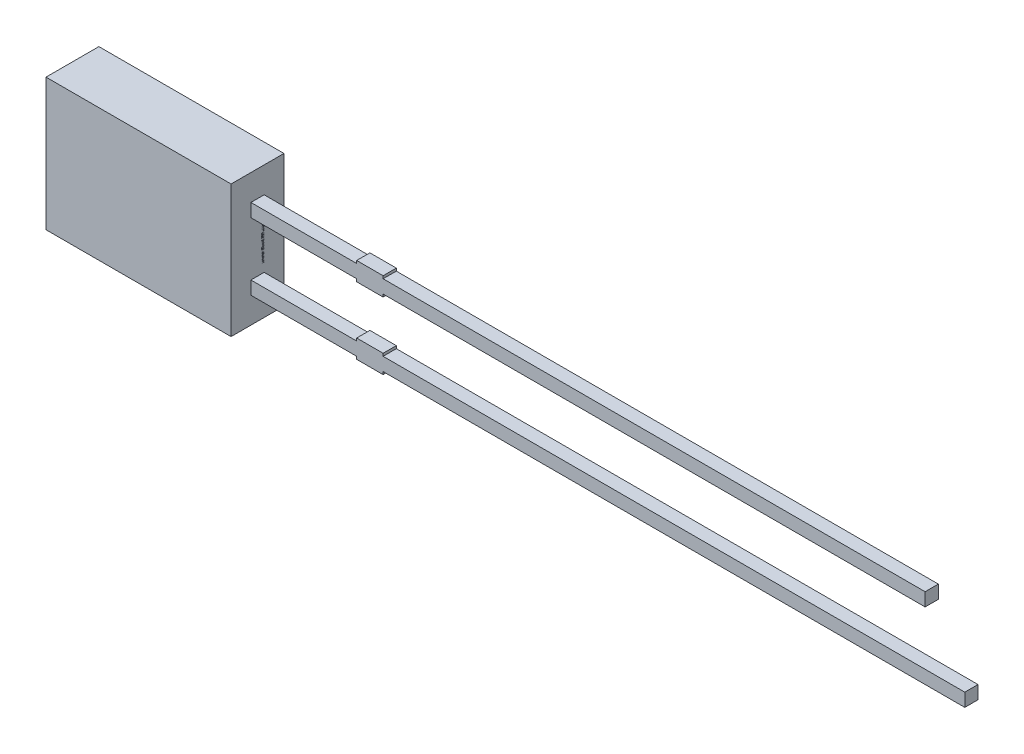
from build123d import *

# Parameters (mm, degrees)
SKETCH1_W          = 7
SKETCH1_H          = 5
EXTRUDE1_DEPTH     = 1
SKETCH1_4_W        = 4
SKETCH1_4_H        = 0.5
SKETCH1_4_W_2      = 1
SKETCH1_4_W_3      = 20.5
SKETCH1_4_H_2      = 0.1
SKETCH1_4_W_4      = 22
EXTRUDE2_DEPTH     = 0.25
SKETCH2_W          = 0.026582278
SKETCH2_H          = 0.025316456
CUT_EXTRUDE1_DEPTH = 0.01


with BuildPart() as part:
    # Sketch1 → Extrude1 (new body, symmetric)
    with BuildSketch(Plane.XY):
        Rectangle(SKETCH1_W, SKETCH1_H)
    extrude(amount=EXTRUDE1_DEPTH, both=True)

    # Sketch1_4 → Extrude2 (add, symmetric)
    with BuildSketch(Plane.XY):
        with Locations((5.5, 1.27)):
            Rectangle(SKETCH1_4_W, SKETCH1_4_H)
        with Locations((8, 1.27)):
            Rectangle(SKETCH1_4_W_2, SKETCH1_4_H)
        with Locations((18.75, 1.27)):
            Rectangle(SKETCH1_4_W_3, SKETCH1_4_H)
        with Locations((8, 1.57)):
            Rectangle(SKETCH1_4_W_2, SKETCH1_4_H_2)
        with Locations((8, 0.97)):
            Rectangle(SKETCH1_4_W_2, SKETCH1_4_H_2)
        with Locations((8, -1.27)):
            Rectangle(SKETCH1_4_W_2, SKETCH1_4_H)
        with Locations((8, -0.97)):
            Rectangle(SKETCH1_4_W_2, SKETCH1_4_H_2)
        with Locations((19.5, -1.27)):
            Rectangle(SKETCH1_4_W_4, SKETCH1_4_H)
        with Locations((5.5, -1.27)):
            Rectangle(SKETCH1_4_W, SKETCH1_4_H)
        with Locations((8, -1.57)):
            Rectangle(SKETCH1_4_W_2, SKETCH1_4_H_2)
    extrude(amount=EXTRUDE2_DEPTH, both=True)

    # Sketch2 → Cut-Extrude1 (cut)
    with BuildSketch(Plane(origin=(3.5, 0, 0), x_dir=(0, 0, -1), z_dir=(1, 0, 0))):
        Polygon((0.175316456, -0.572151899), (0.25, -0.595609177), (0.25, -0.620352057), (0.199663766, -0.636768196), (0.25, -0.652294304), (0.25, -0.678026108), (0.175316456, -0.701265823), (0.175316456, -0.676087816), (0.226799842, -0.663093354), (0.175316456, -0.646677215), (0.175316456, -0.625178006), (0.226799842, -0.608860759), (0.175316456, -0.596044304), align=None)
        Polygon((0.175316456, -0.437974684), (0.25, -0.461431962), (0.25, -0.486174842), (0.199663766, -0.502590981), (0.25, -0.518117089), (0.25, -0.543848892), (0.175316456, -0.567088608), (0.175316456, -0.541910601), (0.226799842, -0.528916139), (0.175316456, -0.5125), (0.175316456, -0.491000791), (0.226799842, -0.474683544), (0.175316456, -0.461867089), align=None)
        Polygon((0.175316456, -0.303797468), (0.25, -0.327254747), (0.25, -0.351997627), (0.199663766, -0.368413766), (0.25, -0.383939873), (0.25, -0.409671677), (0.175316456, -0.432911392), (0.175316456, -0.407733386), (0.226799842, -0.394738924), (0.175316456, -0.378322785), (0.175316456, -0.356823576), (0.226799842, -0.340506329), (0.175316456, -0.327689873), align=None)
        with Locations((0.236708861, -0.275949367)):
            Rectangle(SKETCH2_W, SKETCH2_H)
        with BuildLine():
            add(Edge.make_bspline(
                [(0.218829114, -0.159493671), (0.220051236, -0.15953019), (0.222451075, -0.159601901), (0.225958932, -0.160211194), (0.229282615, -0.161206237), (0.232443853, -0.162572352), (0.23540828, -0.164381718), (0.238204295, -0.166563022), (0.240818493, -0.169150529), (0.24322702, -0.17210691), (0.245431684, -0.175388005), (0.24732279, -0.178990487), (0.248949325, -0.182859482), (0.2502805, -0.187013878), (0.251271415, -0.191459348), (0.25199469, -0.196177156), (0.252468209, -0.201170496), (0.252510149, -0.204594085), (0.252531646, -0.206348892)],
                knots=[0, 0, 0, 0, 0.907462679, 1.781953809, 2.635804048, 3.480274448, 4.332887508, 5.208817748, 6.109340518, 7.059474472, 8.037577805, 9.041105121, 10.077237313, 11.152245627, 12.27748741, 13.457227022, 14.696666784, 16, 16, 16, 16], degree=3))
            add(Edge.make_bspline(
                [(0.252531646, -0.206348892), (0.252504381, -0.208366877), (0.252451577, -0.212275063), (0.252066204, -0.217942631), (0.251378254, -0.223206098), (0.250421674, -0.228103845), (0.249218389, -0.232708145), (0.247927745, -0.23714149), (0.246463164, -0.241422782), (0.245363028, -0.244195874), (0.244818038, -0.24556962)],
                knots=[0, 0, 0, 0, 1.203182053, 2.33017619, 3.384818652, 4.366208123, 5.30340534, 6.221361684, 7.118890722, 8, 8, 8, 8], degree=3))
            Line((0.244818038, -0.24556962), (0.220886076, -0.24556962))
            Line((0.220886076, -0.24556962), (0.220886076, -0.242721519))
            add(Edge.make_bspline(
                [(0.220886076, -0.242721519), (0.221967039, -0.241355956), (0.224122618, -0.238632846), (0.226890972, -0.234205888), (0.229263982, -0.229546876), (0.231246605, -0.224708482), (0.232822219, -0.219807114), (0.233949125, -0.214938046), (0.234688489, -0.210169064), (0.23477005, -0.207010742), (0.234810127, -0.205458861)],
                knots=[0, 0, 0, 0, 1.030738938, 2.055426519, 3.085610749, 4.123842265, 5.148648843, 6.130724483, 7.081507926, 8, 8, 8, 8], degree=3))
            add(Edge.make_bspline(
                [(0.234810127, -0.205458861), (0.23480879, -0.205030118), (0.234805929, -0.204112212), (0.234685817, -0.202649556), (0.234555416, -0.201000033), (0.234361419, -0.199225642), (0.234127047, -0.197432474), (0.233785865, -0.195764575), (0.233413757, -0.194257809), (0.233046659, -0.193351105), (0.232871835, -0.192919304)],
                knots=[0, 0, 0, 0, 0.806557331, 1.726776592, 2.760222249, 3.920734434, 5.085813889, 6.161303184, 7.124353598, 8, 8, 8, 8], degree=3))
            add(Edge.make_bspline(
                [(0.232871835, -0.192919304), (0.232643282, -0.192440047), (0.232194127, -0.191498205), (0.231387464, -0.190196887), (0.230480651, -0.189041565), (0.229519264, -0.18798482), (0.228368617, -0.187098496), (0.226961414, -0.186481634), (0.225313428, -0.186135268), (0.22413807, -0.186096466), (0.223516614, -0.186075949)],
                knots=[0, 0, 0, 0, 1.025060442, 2.01446193, 2.949256246, 3.85908539, 4.768290539, 5.73153362, 6.800575992, 8, 8, 8, 8], degree=3))
            add(Edge.make_bspline(
                [(0.223516614, -0.186075949), (0.222971006, -0.186107814), (0.221898181, -0.186170468), (0.220362632, -0.186747374), (0.21895522, -0.187657973), (0.217681809, -0.188931946), (0.216563537, -0.190544736), (0.215540893, -0.192462318), (0.21471198, -0.194733369), (0.214273386, -0.196370181), (0.214042722, -0.197231013)],
                knots=[0, 0, 0, 0, 0.825786558, 1.623739628, 2.456775365, 3.355767579, 4.339087636, 5.42728423, 6.646958453, 8, 8, 8, 8], degree=3))
            add(Edge.make_bspline(
                [(0.214042722, -0.197231013), (0.213597012, -0.199200151), (0.212682272, -0.203241458), (0.211503178, -0.209382993), (0.210268525, -0.21551983), (0.209057108, -0.219470134), (0.20846519, -0.221400316)],
                knots=[0, 0, 0, 0, 0.976116373, 2.003306214, 3.02438349, 4, 4, 4, 4], degree=3))
            add(Edge.make_bspline(
                [(0.20846519, -0.221400316), (0.20811147, -0.222438472), (0.20742292, -0.224459338), (0.206270237, -0.227358497), (0.204965225, -0.23000186), (0.203642765, -0.232459004), (0.202164164, -0.234653033), (0.200623419, -0.236646745), (0.198984461, -0.238419051), (0.197227076, -0.239944561), (0.195392008, -0.241289007), (0.193443793, -0.242440034), (0.191382477, -0.243408151), (0.18921802, -0.244200582), (0.18694876, -0.244819413), (0.18457149, -0.245239559), (0.182088239, -0.245538255), (0.180393871, -0.245559023), (0.179529272, -0.24556962)],
                knots=[0, 0, 0, 0, 1.287139616, 2.505537848, 3.65787682, 4.745319116, 5.777517297, 6.75878323, 7.700384896, 8.605120322, 9.485712598, 10.366814604, 11.256335458, 12.154696155, 13.068779358, 14.012730507, 14.985940713, 16, 16, 16, 16], degree=3))
            add(Edge.make_bspline(
                [(0.179529272, -0.24556962), (0.178373126, -0.24553232), (0.176097851, -0.245458913), (0.172768828, -0.244857463), (0.16962001, -0.243830953), (0.166616854, -0.242444593), (0.16380259, -0.2406171), (0.161125104, -0.238424977), (0.158632608, -0.235814667), (0.156333971, -0.23282934), (0.154255166, -0.229542493), (0.152418458, -0.226008488), (0.150912011, -0.222229636), (0.14963078, -0.218249751), (0.148678384, -0.214030359), (0.147958807, -0.209593388), (0.147545806, -0.204919526), (0.147494531, -0.201728115), (0.147468354, -0.200098892)],
                knots=[0, 0, 0, 0, 0.894901293, 1.761149761, 2.608783409, 3.453876344, 4.314933854, 5.200038827, 6.12799933, 7.103249695, 8.113098521, 9.136064399, 10.182719798, 11.259667356, 12.370545059, 13.528828137, 14.738461593, 16, 16, 16, 16], degree=3))
            add(Edge.make_bspline(
                [(0.147468354, -0.200098892), (0.147490709, -0.198430234), (0.14753538, -0.195095747), (0.147910922, -0.190113874), (0.14847452, -0.185162543), (0.149281503, -0.180292383), (0.150290966, -0.17560825), (0.151380413, -0.171185772), (0.152620339, -0.167106707), (0.153574441, -0.164532994), (0.15403481, -0.163291139)],
                knots=[0, 0, 0, 0, 1.065384654, 2.128962885, 3.18847586, 4.246683315, 5.279600907, 6.247539799, 7.154412252, 8, 8, 8, 8], degree=3))
            Line((0.15403481, -0.163291139), (0.176582278, -0.163291139))
            Line((0.176582278, -0.163291139), (0.176582278, -0.166119462))
            add(Edge.make_bspline(
                [(0.176582278, -0.166119462), (0.175783133, -0.16719302), (0.174152259, -0.16938391), (0.172048226, -0.173032632), (0.170116523, -0.177006091), (0.168387193, -0.181273774), (0.166968062, -0.185747065), (0.165938626, -0.190324411), (0.165299605, -0.194951528), (0.165226459, -0.198053112), (0.165189873, -0.19960443)],
                knots=[0, 0, 0, 0, 0.892231706, 1.82084296, 2.804411717, 3.838445872, 4.890103822, 5.931567007, 6.965432763, 8, 8, 8, 8], degree=3))
            add(Edge.make_bspline(
                [(0.165189873, -0.19960443), (0.165214522, -0.200699669), (0.165263948, -0.202895847), (0.165607428, -0.206171246), (0.166287131, -0.209404419), (0.167098237, -0.211441491), (0.167503956, -0.212460443)],
                knots=[0, 0, 0, 0, 0.99896713, 2.003134239, 3.001159596, 4, 4, 4, 4], degree=3))
            add(Edge.make_bspline(
                [(0.167503956, -0.212460443), (0.16770515, -0.212894149), (0.168107405, -0.21376127), (0.168886797, -0.214969172), (0.169804037, -0.216088766), (0.170857301, -0.217093311), (0.172038369, -0.217917451), (0.17330104, -0.218558729), (0.174663973, -0.218918158), (0.175598013, -0.218964182), (0.176068038, -0.218987342)],
                knots=[0, 0, 0, 0, 1.005120364, 2.009570296, 3.014977851, 4.045438181, 5.061509448, 6.035608779, 7.011484765, 8, 8, 8, 8], degree=3))
            add(Edge.make_bspline(
                [(0.176068038, -0.218987342), (0.176705969, -0.218952547), (0.177924997, -0.218886059), (0.179638693, -0.218286061), (0.181101805, -0.217288392), (0.182094798, -0.216135293), (0.182793558, -0.215018314), (0.183298798, -0.213977797), (0.183812221, -0.212778346), (0.184301418, -0.211400897), (0.184795464, -0.209865762), (0.185270134, -0.20815684), (0.185719693, -0.206274232), (0.186005845, -0.204958342), (0.186155063, -0.204272152)],
                knots=[0, 0, 0, 0, 1.174343879, 2.244064321, 3.303704314, 4.407076671, 5.02483983, 5.732197225, 6.53898402, 7.431906431, 8.428480183, 9.514816237, 10.704066255, 12, 12, 12, 12], degree=3))
            add(Edge.make_bspline(
                [(0.186155063, -0.204272152), (0.186531164, -0.202439393), (0.187268822, -0.198844747), (0.188372053, -0.193441658), (0.189674916, -0.187946356), (0.190807308, -0.184269987), (0.191396361, -0.182357595)],
                knots=[0, 0, 0, 0, 0.995794372, 1.953081347, 2.935223864, 4, 4, 4, 4], degree=3))
            add(Edge.make_bspline(
                [(0.191396361, -0.182357595), (0.191715717, -0.181411104), (0.19234043, -0.179559616), (0.19342515, -0.176918101), (0.194607113, -0.174468933), (0.195830039, -0.172191063), (0.197191731, -0.170127593), (0.198609062, -0.168242758), (0.200115036, -0.166545595), (0.201730389, -0.165056465), (0.203441066, -0.163728463), (0.205290718, -0.162613457), (0.207239881, -0.161626842), (0.209320315, -0.160835225), (0.211531277, -0.160250746), (0.213858161, -0.159818068), (0.216303313, -0.159526859), (0.217977782, -0.159504857), (0.218829114, -0.159493671)],
                knots=[0, 0, 0, 0, 1.237247399, 2.420255609, 3.534416354, 4.605351393, 5.620193117, 6.593738998, 7.524982051, 8.426564095, 9.311945829, 10.20281032, 11.097671666, 12.01534975, 12.954438892, 13.926750701, 14.945921247, 16, 16, 16, 16], degree=3))
        make_face()
        with BuildLine():
            Line((0.25, -0.067088608), (0.25, -0.091139241))
            Line((0.25, -0.091139241), (0.242167722, -0.091139241))
            add(Edge.make_bspline(
                [(0.242167722, -0.091139241), (0.242976625, -0.092232381), (0.244536179, -0.094339941), (0.246611792, -0.097515206), (0.248404118, -0.100536174), (0.249910142, -0.103474602), (0.251137796, -0.106474005), (0.251949951, -0.109708164), (0.252454032, -0.113209191), (0.2525052, -0.115636342), (0.252531646, -0.116890823)],
                knots=[0, 0, 0, 0, 1.15097647, 2.219065785, 3.209751872, 4.123278731, 5.012494873, 5.946522673, 6.938654008, 8, 8, 8, 8], degree=3))
            add(Edge.make_bspline(
                [(0.252531646, -0.116890823), (0.252508688, -0.117907091), (0.252463982, -0.11988606), (0.2521224, -0.122764448), (0.2515735, -0.125466099), (0.250806818, -0.127996041), (0.249795405, -0.130347067), (0.248544706, -0.132504746), (0.247082839, -0.134491413), (0.245406585, -0.136295066), (0.243485438, -0.137885611), (0.241362738, -0.139272682), (0.239028085, -0.140448488), (0.236476722, -0.141390128), (0.233718277, -0.142145061), (0.230739071, -0.142669038), (0.227551931, -0.142989618), (0.225356803, -0.143021559), (0.224228639, -0.143037975)],
                knots=[0, 0, 0, 0, 1.108887696, 2.159324556, 3.158383213, 4.114277414, 5.039206009, 5.945047284, 6.830075132, 7.726032535, 8.625162295, 9.545152215, 10.487958828, 11.471559655, 12.508379831, 13.604991163, 14.769110247, 16, 16, 16, 16], degree=3))
            Line((0.224228639, -0.143037975), (0.175316456, -0.143037975))
            Line((0.175316456, -0.143037975), (0.175316456, -0.118987342))
            Line((0.175316456, -0.118987342), (0.21289557, -0.118987342))
            add(Edge.make_bspline(
                [(0.21289557, -0.118987342), (0.213812041, -0.118985706), (0.215566256, -0.118982576), (0.218072063, -0.118900237), (0.220340235, -0.118779336), (0.222382264, -0.118640631), (0.224229015, -0.118387615), (0.225895176, -0.118009906), (0.227414778, -0.11753908), (0.228321479, -0.117074761), (0.228757911, -0.116851266)],
                knots=[0, 0, 0, 0, 1.361401701, 2.605856924, 3.723918663, 4.735739235, 5.645738665, 6.489217889, 7.27279937, 8, 8, 8, 8], degree=3))
            add(Edge.make_bspline(
                [(0.228757911, -0.116851266), (0.22915655, -0.116621224), (0.229940239, -0.116168982), (0.23094752, -0.115249197), (0.231783912, -0.114173114), (0.232458611, -0.112903872), (0.232933771, -0.111407752), (0.233320951, -0.109682844), (0.233491169, -0.107690452), (0.23352591, -0.106283083), (0.233544304, -0.105537975)],
                knots=[0, 0, 0, 0, 0.848923305, 1.668910138, 2.502822694, 3.358979167, 4.311113223, 5.396624103, 6.621686681, 8, 8, 8, 8], degree=3))
            add(Edge.make_bspline(
                [(0.233544304, -0.105537975), (0.233524355, -0.104997054), (0.233483369, -0.103885683), (0.233294338, -0.102174294), (0.232890178, -0.100392654), (0.232246209, -0.097874301), (0.231059246, -0.094699608), (0.229701719, -0.092335231), (0.229015032, -0.091139241)],
                knots=[0, 0, 0, 0, 0.638098464, 1.31103257, 2.025970928, 2.789492669, 4.376004971, 6, 6, 6, 6], degree=3))
            Line((0.229015032, -0.091139241), (0.175316456, -0.091139241))
            Line((0.175316456, -0.091139241), (0.175316456, -0.067088608))
            Line((0.175316456, -0.067088608), (0.25, -0.067088608))
        make_face()
        with BuildLine():
            Line((0.25, 0.030379747), (0.25, 0.006329114))
            Line((0.25, 0.006329114), (0.212420886, 0.006329114))
            add(Edge.make_bspline(
                [(0.212420886, 0.006329114), (0.210890463, 0.006308303), (0.20783158, 0.006266709), (0.204074178, 0.005938503), (0.201227102, 0.005599031), (0.199397351, 0.005224273), (0.197849034, 0.004793931), (0.196963295, 0.004381503), (0.196558544, 0.004193038)],
                knots=[0, 0, 0, 0, 1.709225407, 3.416259723, 4.21101956, 4.910102269, 5.501957085, 6, 6, 6, 6], degree=3))
            add(Edge.make_bspline(
                [(0.196558544, 0.004193038), (0.196160412, 0.003948611), (0.195379818, 0.003469379), (0.194367934, 0.002531536), (0.19353119, 0.001434991), (0.192868341, 0.000155857), (0.192373933, -0.001325729), (0.192027651, -0.003045559), (0.191815428, -0.005025093), (0.191787128, -0.00643402), (0.191772152, -0.007179589)],
                knots=[0, 0, 0, 0, 0.860284341, 1.686708632, 2.528476982, 3.393563585, 4.332150703, 5.400907339, 6.624626855, 8, 8, 8, 8], degree=3))
            add(Edge.make_bspline(
                [(0.191772152, -0.007179589), (0.191832097, -0.008310545), (0.191954421, -0.010618379), (0.192623154, -0.013492792), (0.193476383, -0.015806428), (0.194242298, -0.017657215), (0.195199597, -0.019572829), (0.195926288, -0.020856385), (0.196301424, -0.021518987)],
                knots=[0, 0, 0, 0, 1.338233385, 2.730803257, 3.468495571, 4.255080394, 5.099229486, 6, 6, 6, 6], degree=3))
            Line((0.196301424, -0.021518987), (0.25, -0.021518987))
            Line((0.25, -0.021518987), (0.25, -0.04556962))
            Line((0.25, -0.04556962), (0.175316456, -0.04556962))
            Line((0.175316456, -0.04556962), (0.175316456, -0.021518987))
            Line((0.175316456, -0.021518987), (0.183148734, -0.021518987))
            add(Edge.make_bspline(
                [(0.183148734, -0.021518987), (0.182342296, -0.02046175), (0.180772517, -0.018403774), (0.178739108, -0.015227022), (0.176929251, -0.01215631), (0.175417117, -0.009101788), (0.174218517, -0.005977291), (0.173402914, -0.00270966), (0.172859966, 0.000707053), (0.172810154, 0.003043726), (0.17278481, 0.004232595)],
                knots=[0, 0, 0, 0, 1.126064518, 2.191951536, 3.19307265, 4.144813015, 5.076393104, 6.021983703, 6.993610568, 8, 8, 8, 8], degree=3))
            add(Edge.make_bspline(
                [(0.17278481, 0.004232595), (0.172810211, 0.00522886), (0.172859797, 0.007173746), (0.173169348, 0.010008596), (0.173720571, 0.012679702), (0.174516428, 0.015173087), (0.175507788, 0.01750877), (0.176711763, 0.019682454), (0.17817506, 0.021668259), (0.179834938, 0.023496579), (0.181726466, 0.025135042), (0.183854957, 0.026534404), (0.186197444, 0.027730277), (0.188746989, 0.028717595), (0.191525947, 0.029468634), (0.194519327, 0.029984818), (0.197730225, 0.030339095), (0.199946231, 0.030365925), (0.201087816, 0.030379747)],
                knots=[0, 0, 0, 0, 1.088244909, 2.124447647, 3.110254678, 4.062235362, 4.978491991, 5.877983887, 6.769571508, 7.666696544, 8.570415953, 9.495151274, 10.442024977, 11.43832337, 12.476026402, 13.580659577, 14.753665747, 16, 16, 16, 16], degree=3))
            Line((0.201087816, 0.030379747), (0.25, 0.030379747))
        make_face()
        Polygon((0.25, 0.125316456), (0.25, 0.053164557), (0.15, 0.053164557), (0.15, 0.078481013), (0.231012658, 0.078481013), (0.231012658, 0.125316456), align=None)
        Polygon((0.25, 0.212658228), (0.25, 0.140506329), (0.15, 0.140506329), (0.15, 0.212658228), (0.168987342, 0.212658228), (0.168987342, 0.165822785), (0.186708861, 0.165822785), (0.186708861, 0.208860759), (0.205696203, 0.208860759), (0.205696203, 0.165822785), (0.231012658, 0.165822785), (0.231012658, 0.212658228), align=None)
        with BuildLine():
            add(Edge.make_bspline(
                [(0.200098892, 0.329113924), (0.201246581, 0.329094609), (0.203519467, 0.329056357), (0.206884274, 0.328761165), (0.210149949, 0.32823514), (0.213334198, 0.327555959), (0.216413126, 0.326633453), (0.219420703, 0.325551739), (0.222326196, 0.324242093), (0.225127631, 0.322737241), (0.227799734, 0.321087768), (0.230319942, 0.319313019), (0.23270316, 0.31746724), (0.234898054, 0.315477927), (0.236940074, 0.313398746), (0.238830888, 0.311223217), (0.240534319, 0.308918153), (0.241557203, 0.30731099), (0.242068829, 0.30650712)],
                knots=[0, 0, 0, 0, 1.105570398, 2.18947457, 3.250358341, 4.290584537, 5.323553275, 6.344225964, 7.367641686, 8.3905646, 9.405808457, 10.390761353, 11.358902336, 12.307789878, 13.241960776, 14.165076779, 15.082208636, 16, 16, 16, 16], degree=3))
            add(Edge.make_bspline(
                [(0.242068829, 0.30650712), (0.24278118, 0.30526794), (0.244209516, 0.302783257), (0.245874907, 0.298798692), (0.247292943, 0.294671424), (0.248300154, 0.290304109), (0.249071633, 0.285666021), (0.249622116, 0.280667978), (0.249926212, 0.275267531), (0.249974844, 0.27153255), (0.25, 0.269600475)],
                knots=[0, 0, 0, 0, 0.896331627, 1.797236794, 2.705411718, 3.632841792, 4.606367508, 5.655603524, 6.787262262, 8, 8, 8, 8], degree=3))
            Line((0.25, 0.269600475), (0.25, 0.234177215))
            Line((0.25, 0.234177215), (0.15, 0.234177215))
            Line((0.15, 0.234177215), (0.15, 0.270609177))
            add(Edge.make_bspline(
                [(0.15, 0.270609177), (0.150016894, 0.272587865), (0.150049481, 0.276404509), (0.150462791, 0.281915405), (0.151071212, 0.287010921), (0.151967221, 0.291699732), (0.153075107, 0.296010589), (0.154467575, 0.299933416), (0.15595976, 0.303549763), (0.157234368, 0.305728284), (0.157852057, 0.306784019)],
                knots=[0, 0, 0, 0, 1.267100211, 2.444079055, 3.537724964, 4.552266402, 5.499704501, 6.385138932, 7.217420793, 8, 8, 8, 8], degree=3))
            add(Edge.make_bspline(
                [(0.157852057, 0.306784019), (0.158388598, 0.307634972), (0.159455511, 0.309327097), (0.161237363, 0.311728312), (0.16319344, 0.313957739), (0.165245259, 0.316086242), (0.167448147, 0.318066056), (0.16978685, 0.319909269), (0.172264957, 0.321613036), (0.174874377, 0.323171192), (0.177604617, 0.324591277), (0.180476962, 0.325783356), (0.183459835, 0.326822718), (0.186558775, 0.327668801), (0.189776165, 0.32832513), (0.193113645, 0.328771214), (0.196566833, 0.329054647), (0.198911627, 0.329093999), (0.200098892, 0.329113924)],
                knots=[0, 0, 0, 0, 0.964043478, 1.917004671, 2.862223898, 3.805158963, 4.749279098, 5.698713747, 6.657523689, 7.629652222, 8.610369353, 9.604453025, 10.607693792, 11.636365947, 12.681120053, 13.752669011, 14.862083412, 16, 16, 16, 16], degree=3))
        make_face()
        with BuildLine():
            add(Edge.make_bspline(
                [(0.199940665, 0.302531646), (0.198362809, 0.302485243), (0.195317141, 0.302395675), (0.190912939, 0.301732132), (0.186879674, 0.300552601), (0.18376317, 0.299223365), (0.181490155, 0.297884821), (0.179891824, 0.296757527), (0.178377641, 0.295507799), (0.176968796, 0.294117207), (0.175661761, 0.292582018), (0.17443285, 0.29092076), (0.173304205, 0.289120719), (0.172644199, 0.287847687), (0.172310127, 0.287203323)],
                knots=[0, 0, 0, 0, 1.694561208, 3.270940604, 4.767926833, 6.198032689, 6.896357436, 7.597727349, 8.296769799, 9.00280713, 9.720956486, 10.460265288, 11.220639329, 12, 12, 12, 12], degree=3))
            add(Edge.make_bspline(
                [(0.172310127, 0.287203323), (0.172003612, 0.286528388), (0.171396079, 0.285190619), (0.170661993, 0.283120344), (0.170099666, 0.281027643), (0.169627243, 0.278833415), (0.169350107, 0.276356655), (0.169137431, 0.273434164), (0.169000503, 0.269977491), (0.168991932, 0.267490895), (0.168987342, 0.266159019)],
                knots=[0, 0, 0, 0, 0.826913061, 1.638999358, 2.447478739, 3.243919028, 4.140906711, 5.225381046, 6.513851968, 8, 8, 8, 8], degree=3))
            Line((0.168987342, 0.266159019), (0.168987342, 0.259493671))
            Line((0.168987342, 0.259493671), (0.231012658, 0.259493671))
            Line((0.231012658, 0.259493671), (0.231012658, 0.266159019))
            add(Edge.make_bspline(
                [(0.231012658, 0.266159019), (0.231007616, 0.266917211), (0.230997882, 0.268380947), (0.23095873, 0.270497394), (0.230898581, 0.272462176), (0.230826183, 0.274269462), (0.230713532, 0.275919264), (0.230539542, 0.277406458), (0.230402845, 0.278743267), (0.230125721, 0.280315786), (0.229719474, 0.282170955), (0.229036403, 0.28433775), (0.228186805, 0.286478448), (0.227501729, 0.287866999), (0.227155854, 0.288568038)],
                knots=[0, 0, 0, 0, 1.186788252, 2.291168447, 3.31326867, 4.263560303, 5.122314491, 5.900668105, 6.60723418, 7.224768558, 8.398927205, 9.577205322, 10.776800932, 12, 12, 12, 12], degree=3))
            add(Edge.make_bspline(
                [(0.227155854, 0.288568038), (0.226812376, 0.28915175), (0.22613689, 0.290299682), (0.22503105, 0.291943861), (0.223795966, 0.293430472), (0.222513174, 0.294836999), (0.221121595, 0.29608816), (0.219678055, 0.297265459), (0.218103513, 0.2982507), (0.215914578, 0.29949957), (0.212887421, 0.300743145), (0.208915497, 0.301776761), (0.204556343, 0.302415553), (0.201518637, 0.302491957), (0.199940665, 0.302531646)],
                knots=[0, 0, 0, 0, 0.755184287, 1.485151634, 2.206180267, 2.908413556, 3.605665444, 4.291074465, 4.982332562, 5.673512475, 7.100235687, 8.614142391, 10.24117603, 12, 12, 12, 12], degree=3))
        make_face(mode=Mode.SUBTRACT)
        with Locations((0.236708861, 0.360759494)):
            Rectangle(SKETCH2_W, SKETCH2_H)
        with BuildLine():
            add(Edge.make_bspline(
                [(0.252531646, 0.435403481), (0.252509827, 0.433813372), (0.252467001, 0.430692242), (0.251990188, 0.426120851), (0.251272118, 0.421755856), (0.25025254, 0.417608916), (0.248903167, 0.413705632), (0.247268095, 0.410033248), (0.245268257, 0.406634041), (0.24368564, 0.404567057), (0.242899525, 0.403540348)],
                knots=[0, 0, 0, 0, 1.123640227, 2.2055255, 3.245221982, 4.248949655, 5.220213072, 6.160941522, 7.086505793, 8, 8, 8, 8], degree=3))
            add(Edge.make_bspline(
                [(0.242899525, 0.403540348), (0.242044692, 0.402588713), (0.240338332, 0.400689124), (0.237367788, 0.398221497), (0.234078815, 0.396103421), (0.230487163, 0.394291165), (0.226567277, 0.392859214), (0.222317383, 0.391866679), (0.217760053, 0.391239075), (0.214611849, 0.391173123), (0.212994462, 0.391139241)],
                knots=[0, 0, 0, 0, 0.916342154, 1.829140869, 2.758848968, 3.716597128, 4.708179637, 5.743612459, 6.840783343, 8, 8, 8, 8], degree=3))
            add(Edge.make_bspline(
                [(0.212994462, 0.391139241), (0.211291235, 0.391178001), (0.207990155, 0.391253124), (0.203217967, 0.391916883), (0.198800287, 0.392986496), (0.194748378, 0.394524054), (0.191055187, 0.396454496), (0.187683352, 0.398718989), (0.184640428, 0.401339514), (0.182894988, 0.403346653), (0.182021361, 0.404351266)],
                knots=[0, 0, 0, 0, 1.171797512, 2.271099083, 3.308930235, 4.294129479, 5.24602549, 6.17106565, 7.084581485, 8, 8, 8, 8], degree=3))
            add(Edge.make_bspline(
                [(0.182021361, 0.404351266), (0.181252707, 0.405377093), (0.179706115, 0.407441138), (0.177809395, 0.410840018), (0.176211429, 0.414456691), (0.174936469, 0.418279973), (0.173987224, 0.422262676), (0.173291458, 0.426332115), (0.172863315, 0.430476032), (0.172811104, 0.433266397), (0.17278481, 0.434671677)],
                knots=[0, 0, 0, 0, 0.952013349, 1.915525331, 2.885385798, 3.888123097, 4.906830296, 5.926067872, 6.955529031, 8, 8, 8, 8], degree=3))
            add(Edge.make_bspline(
                [(0.17278481, 0.434671677), (0.172801169, 0.43591849), (0.172833335, 0.438370146), (0.173164493, 0.441968871), (0.17366351, 0.445420869), (0.174407081, 0.448720159), (0.175329895, 0.451886357), (0.176354043, 0.454949807), (0.177493953, 0.457914044), (0.17837791, 0.459814797), (0.178817247, 0.460759494)],
                knots=[0, 0, 0, 0, 1.107572103, 2.177862056, 3.208491727, 4.204802822, 5.180069889, 6.137814326, 7.074472616, 8, 8, 8, 8], degree=3))
            Line((0.178817247, 0.460759494), (0.199367089, 0.460759494))
            Line((0.199367089, 0.460759494), (0.199367089, 0.45741693))
            add(Edge.make_bspline(
                [(0.199367089, 0.45741693), (0.198950197, 0.456917135), (0.19804326, 0.455829843), (0.196616375, 0.454048018), (0.19509511, 0.451893107), (0.194206443, 0.450248438), (0.193730222, 0.449367089)],
                knots=[0, 0, 0, 0, 0.792806788, 1.724728901, 2.780722718, 4, 4, 4, 4], degree=3))
            add(Edge.make_bspline(
                [(0.193730222, 0.449367089), (0.193290676, 0.448438429), (0.192386185, 0.446527444), (0.191521901, 0.443980324), (0.190985918, 0.441780001), (0.190723895, 0.439972051), (0.190536279, 0.43803794), (0.190516496, 0.436702768), (0.190506329, 0.436016614)],
                knots=[0, 0, 0, 0, 1.332411269, 2.741822805, 3.48048496, 4.268099981, 5.109965479, 6, 6, 6, 6], degree=3))
            add(Edge.make_bspline(
                [(0.190506329, 0.436016614), (0.19052567, 0.435250982), (0.190563151, 0.433767223), (0.190843064, 0.431606761), (0.191311637, 0.42958248), (0.191987879, 0.427693249), (0.192848185, 0.425938689), (0.193868345, 0.42430302), (0.195120334, 0.422827378), (0.196538767, 0.421485751), (0.198129091, 0.420298179), (0.19985563, 0.419271451), (0.201713509, 0.418388718), (0.20371142, 0.417686826), (0.205841282, 0.417129316), (0.208104092, 0.416739751), (0.21050369, 0.416497972), (0.212149985, 0.416470029), (0.212994462, 0.416455696)],
                knots=[0, 0, 0, 0, 1.087164589, 2.106874378, 3.088024391, 4.032801718, 4.949890679, 5.859058447, 6.763003849, 7.690312844, 8.626654282, 9.575690722, 10.539030902, 11.54301425, 12.578634972, 13.662366762, 14.800897888, 16, 16, 16, 16], degree=3))
            add(Edge.make_bspline(
                [(0.212994462, 0.416455696), (0.213858618, 0.416470471), (0.215537631, 0.416499177), (0.217979242, 0.416732691), (0.220260673, 0.417148582), (0.222385993, 0.41771983), (0.224352011, 0.418444178), (0.226149408, 0.419349295), (0.227806215, 0.420385652), (0.229268827, 0.42163021), (0.230585149, 0.422994093), (0.231721283, 0.424508985), (0.232669428, 0.426168224), (0.233473891, 0.427950405), (0.234052289, 0.429883445), (0.234488981, 0.431939982), (0.234777538, 0.434129537), (0.234799101, 0.435639891), (0.234810127, 0.436412184)],
                knots=[0, 0, 0, 0, 1.230336593, 2.390482092, 3.487897344, 4.52859895, 5.520747884, 6.465347575, 7.38981449, 8.296085817, 9.192433006, 10.084246191, 10.984321635, 11.908883871, 12.862027947, 13.850751296, 14.901019963, 16, 16, 16, 16], degree=3))
            add(Edge.make_bspline(
                [(0.234810127, 0.436412184), (0.234801272, 0.437137934), (0.234784009, 0.438552757), (0.234576566, 0.440613478), (0.234266178, 0.442563904), (0.233824546, 0.444396174), (0.233319347, 0.446107761), (0.23274215, 0.447669394), (0.232139505, 0.449082516), (0.231671691, 0.449943788), (0.231447785, 0.450356013)],
                knots=[0, 0, 0, 0, 1.201100869, 2.341500598, 3.425337164, 4.468451875, 5.459559168, 6.378110228, 7.223726512, 8, 8, 8, 8], degree=3))
            add(Edge.make_bspline(
                [(0.231447785, 0.450356013), (0.231020099, 0.451064369), (0.23019814, 0.452425742), (0.22877768, 0.454250861), (0.22737124, 0.455894986), (0.226414472, 0.456919091), (0.225949367, 0.45741693)],
                knots=[0, 0, 0, 0, 1.105932972, 2.12546697, 3.088749538, 4, 4, 4, 4], degree=3))
            Line((0.225949367, 0.45741693), (0.225949367, 0.460759494))
            Line((0.225949367, 0.460759494), (0.246657437, 0.460759494))
            add(Edge.make_bspline(
                [(0.246657437, 0.460759494), (0.247094979, 0.459814117), (0.247970168, 0.457923136), (0.249123319, 0.455008359), (0.250096198, 0.452015116), (0.250988545, 0.448963886), (0.25168674, 0.445794254), (0.25217597, 0.442476905), (0.252477709, 0.438995601), (0.252513421, 0.436617185), (0.252531646, 0.435403481)],
                knots=[0, 0, 0, 0, 0.952024047, 1.90427691, 2.862762905, 3.827874523, 4.80891974, 5.826446878, 6.890837857, 8, 8, 8, 8], degree=3))
        make_face()
        with BuildLine():
            add(Edge.make_bspline(
                [(0.212697785, 0.553164557), (0.214202617, 0.553139637), (0.217135938, 0.553091062), (0.221408758, 0.552554854), (0.225439199, 0.551731391), (0.229240037, 0.550598066), (0.232783083, 0.549080213), (0.236079037, 0.547237799), (0.239131219, 0.545064208), (0.241921446, 0.542573889), (0.244419638, 0.539772404), (0.246615831, 0.536698638), (0.248422879, 0.533328772), (0.249949428, 0.529720026), (0.251105529, 0.525830719), (0.25192348, 0.521671624), (0.252457811, 0.517254115), (0.252506624, 0.514215749), (0.252531646, 0.512658228)],
                knots=[0, 0, 0, 0, 1.120122129, 2.18341868, 3.201215738, 4.181270334, 5.131540819, 6.065757527, 6.988093576, 7.916512302, 8.844931028, 9.778115023, 10.722851943, 11.686686084, 12.691660064, 13.738321946, 14.84062285, 16, 16, 16, 16], degree=3))
            add(Edge.make_bspline(
                [(0.252531646, 0.512658228), (0.252506706, 0.51110068), (0.252458054, 0.508062261), (0.251922584, 0.503645127), (0.251109866, 0.499490907), (0.249940631, 0.495606256), (0.248428541, 0.491991945), (0.246615099, 0.488618118), (0.244419846, 0.485543936), (0.241921336, 0.482742733), (0.239131451, 0.480251696), (0.236078221, 0.478080692), (0.232788429, 0.476229753), (0.229231154, 0.47474936), (0.225443946, 0.473576829), (0.221407948, 0.472764049), (0.217136157, 0.472224732), (0.214202691, 0.472176594), (0.212697785, 0.472151899)],
                knots=[0, 0, 0, 0, 1.159424321, 2.261770074, 3.308474541, 4.308788811, 5.277191138, 6.221966496, 7.15518846, 8.08364496, 9.01210146, 9.934475036, 10.868729753, 11.817121636, 12.798654016, 13.816492484, 14.879832297, 16, 16, 16, 16], degree=3))
            add(Edge.make_bspline(
                [(0.212697785, 0.472151899), (0.211186352, 0.472177), (0.208233324, 0.472226044), (0.203934577, 0.472761711), (0.199873481, 0.473578673), (0.19606093, 0.474744205), (0.192498454, 0.476250482), (0.189192265, 0.478097428), (0.186145491, 0.480293183), (0.183355327, 0.482802618), (0.180860799, 0.485615383), (0.178682694, 0.488702882), (0.176873901, 0.492066422), (0.175346136, 0.495666774), (0.17421359, 0.499554435), (0.173395434, 0.503691062), (0.172857525, 0.508088545), (0.17280949, 0.511107271), (0.17278481, 0.512658228)],
                knots=[0, 0, 0, 0, 1.123883205, 2.195836198, 3.217400301, 4.202580581, 5.156396106, 6.089661422, 7.013912723, 7.944661364, 8.875797629, 9.805201257, 10.748976071, 11.711828658, 12.709674189, 13.755270167, 14.846705509, 16, 16, 16, 16], degree=3))
            add(Edge.make_bspline(
                [(0.17278481, 0.512658228), (0.172809522, 0.514228972), (0.172857636, 0.517287148), (0.173393975, 0.521730477), (0.174206501, 0.525904607), (0.175374571, 0.529802216), (0.17687784, 0.533426224), (0.178732787, 0.5367734), (0.180907137, 0.539858359), (0.183436965, 0.542626621), (0.186231919, 0.54511038), (0.189289599, 0.547272736), (0.192597175, 0.549108213), (0.196159051, 0.550583955), (0.199951683, 0.551758158), (0.203986109, 0.552578569), (0.208261016, 0.553084721), (0.211193159, 0.553137483), (0.212697785, 0.553164557)],
                knots=[0, 0, 0, 0, 1.167473013, 2.273023816, 3.322954552, 4.326451713, 5.293391623, 6.234801871, 7.166614545, 8.093305908, 9.017100806, 9.942078766, 10.872536262, 11.824015763, 12.804065898, 13.820367293, 14.881523901, 16, 16, 16, 16], degree=3))
        make_face()
        with BuildLine():
            add(Edge.make_bspline(
                [(0.231190665, 0.523457278), (0.230690401, 0.523811854), (0.229672304, 0.524533458), (0.227972807, 0.525414912), (0.226131019, 0.526165223), (0.224106261, 0.526786059), (0.221815916, 0.527300861), (0.219164963, 0.52759945), (0.216130213, 0.527833002), (0.213977385, 0.52784287), (0.212836234, 0.527848101)],
                knots=[0, 0, 0, 0, 0.765135464, 1.557141201, 2.384449913, 3.246599353, 4.1996426, 5.311961702, 6.575150963, 8, 8, 8, 8], degree=3))
            add(Edge.make_bspline(
                [(0.212836234, 0.527848101), (0.21176136, 0.527830368), (0.209702019, 0.527796392), (0.206742154, 0.527610608), (0.204052656, 0.527259147), (0.201627948, 0.526765631), (0.199455878, 0.526158041), (0.19752355, 0.525423239), (0.195809595, 0.524589801), (0.194804474, 0.523904047), (0.194323576, 0.523575949)],
                knots=[0, 0, 0, 0, 1.337015307, 2.56157572, 3.686511827, 4.707709802, 5.636963675, 6.488272502, 7.276717686, 8, 8, 8, 8], degree=3))
            add(Edge.make_bspline(
                [(0.194323576, 0.523575949), (0.193885931, 0.523237287), (0.193031189, 0.522575862), (0.191924868, 0.521419361), (0.191055061, 0.52013186), (0.190350328, 0.518766917), (0.189874232, 0.517311235), (0.189508645, 0.515811038), (0.189290222, 0.51425344), (0.18925717, 0.513192902), (0.189240506, 0.512658228)],
                knots=[0, 0, 0, 0, 1.058303018, 2.066917725, 3.046948061, 4.023234392, 4.996907708, 5.970172105, 6.976653347, 8, 8, 8, 8], degree=3))
            add(Edge.make_bspline(
                [(0.189240506, 0.512658228), (0.189251536, 0.512130325), (0.18927311, 0.511097766), (0.189451627, 0.509594689), (0.189751626, 0.508179036), (0.190155811, 0.50683387), (0.190767188, 0.505548722), (0.191616005, 0.504317445), (0.192692585, 0.503102058), (0.19354292, 0.50236373), (0.193987342, 0.501977848)],
                knots=[0, 0, 0, 0, 1.04189444, 2.037910168, 2.982338511, 3.896140384, 4.804271323, 5.778885192, 6.839150358, 8, 8, 8, 8], degree=3))
            add(Edge.make_bspline(
                [(0.193987342, 0.501977848), (0.194461009, 0.501642414), (0.195455117, 0.500938424), (0.197175487, 0.500089235), (0.199120978, 0.499319936), (0.201312114, 0.498640648), (0.203779654, 0.498109463), (0.206538267, 0.497751274), (0.209588201, 0.497506594), (0.211721508, 0.497481478), (0.212836234, 0.497468354)],
                knots=[0, 0, 0, 0, 0.70629823, 1.482341141, 2.329662943, 3.254583898, 4.274063958, 5.401087491, 6.641978366, 8, 8, 8, 8], degree=3))
            add(Edge.make_bspline(
                [(0.212836234, 0.497468354), (0.213838969, 0.497474304), (0.215781093, 0.497485828), (0.218583477, 0.497727894), (0.221191744, 0.498015163), (0.223580395, 0.498500249), (0.225769559, 0.499078592), (0.227727699, 0.499811255), (0.229475433, 0.500650609), (0.230499113, 0.501345833), (0.23099288, 0.501681171)],
                knots=[0, 0, 0, 0, 1.270931856, 2.461574991, 3.564842381, 4.596079713, 5.549239655, 6.432768418, 7.244053423, 8, 8, 8, 8], degree=3))
            add(Edge.make_bspline(
                [(0.23099288, 0.501681171), (0.231409784, 0.502021462), (0.232231738, 0.502692369), (0.233306021, 0.503841178), (0.234185641, 0.50510292), (0.234882345, 0.506463378), (0.235415263, 0.507926821), (0.23581568, 0.509481783), (0.236026743, 0.511142692), (0.236059272, 0.512275314), (0.236075949, 0.512856013)],
                knots=[0, 0, 0, 0, 1.011235752, 1.993715204, 2.946409587, 3.894575777, 4.859533504, 5.869856863, 6.907869553, 8, 8, 8, 8], degree=3))
            add(Edge.make_bspline(
                [(0.236075949, 0.512856013), (0.236025396, 0.513864117), (0.235925071, 0.515864737), (0.235183405, 0.518276041), (0.234325663, 0.520072218), (0.233490999, 0.521339493), (0.232426404, 0.522470719), (0.231607882, 0.52312419), (0.231190665, 0.523457278)],
                knots=[0, 0, 0, 0, 1.494110474, 2.96511767, 3.704956058, 4.446088323, 5.207938169, 6, 6, 6, 6], degree=3))
        make_face(mode=Mode.SUBTRACT)
        with BuildLine():
            Line((0.196301424, 0.644303797), (0.25, 0.644303797))
            Line((0.25, 0.644303797), (0.25, 0.620253165))
            Line((0.25, 0.620253165), (0.212143987, 0.620253165))
            add(Edge.make_bspline(
                [(0.212143987, 0.620253165), (0.211253988, 0.620246898), (0.209546423, 0.620234875), (0.207086093, 0.620212363), (0.204838751, 0.620096991), (0.202791415, 0.620000439), (0.20093503, 0.619801755), (0.199255321, 0.619524083), (0.197752325, 0.619095228), (0.19685121, 0.618687802), (0.196420095, 0.61849288)],
                knots=[0, 0, 0, 0, 1.33997484, 2.570892857, 3.703483919, 4.727540125, 5.655929516, 6.512630168, 7.288405602, 8, 8, 8, 8], degree=3))
            add(Edge.make_bspline(
                [(0.196420095, 0.61849288), (0.196034885, 0.618282873), (0.195271303, 0.617866586), (0.194301152, 0.616999731), (0.193497118, 0.615984414), (0.192821546, 0.614820738), (0.1923615, 0.613425719), (0.192000355, 0.611817719), (0.191823871, 0.609952288), (0.191790041, 0.608630238), (0.191772152, 0.607931171)],
                knots=[0, 0, 0, 0, 0.859137151, 1.703023591, 2.531884144, 3.395689496, 4.329139829, 5.403231912, 6.626892925, 8, 8, 8, 8], degree=3))
            add(Edge.make_bspline(
                [(0.191772152, 0.607931171), (0.191795018, 0.607343691), (0.191840957, 0.606163433), (0.192093687, 0.604403162), (0.192557472, 0.602668945), (0.193402753, 0.600450118), (0.194647862, 0.597858933), (0.195763692, 0.595887005), (0.196301424, 0.594936709)],
                knots=[0, 0, 0, 0, 0.759205818, 1.525260036, 2.291692926, 3.073215079, 4.589547174, 6, 6, 6, 6], degree=3))
            Line((0.196301424, 0.594936709), (0.25, 0.594936709))
            Line((0.25, 0.594936709), (0.25, 0.570886076))
            Line((0.25, 0.570886076), (0.175316456, 0.570886076))
            Line((0.175316456, 0.570886076), (0.175316456, 0.594936709))
            Line((0.175316456, 0.594936709), (0.183148734, 0.594936709))
            add(Edge.make_bspline(
                [(0.183148734, 0.594936709), (0.182366873, 0.595957498), (0.180848815, 0.597939458), (0.17880616, 0.60095963), (0.177026096, 0.603901326), (0.175475652, 0.606795115), (0.174264938, 0.609757591), (0.173415278, 0.612850643), (0.172886216, 0.616094734), (0.172819023, 0.618312831), (0.17278481, 0.619442247)],
                knots=[0, 0, 0, 0, 1.135996309, 2.205644619, 3.219721285, 4.173434518, 5.103784725, 6.040859173, 7.002439823, 8, 8, 8, 8], degree=3))
            add(Edge.make_bspline(
                [(0.17278481, 0.619442247), (0.172816742, 0.620645387), (0.172879151, 0.622996841), (0.173545796, 0.626410207), (0.174559074, 0.629618041), (0.176014514, 0.632594214), (0.177887184, 0.635295415), (0.180138035, 0.637716747), (0.182807568, 0.639805169), (0.184812476, 0.640896925), (0.185838608, 0.641455696)],
                knots=[0, 0, 0, 0, 1.065874838, 2.083178459, 3.072535385, 4.042784727, 5.009538681, 5.977671113, 6.9649521, 8, 8, 8, 8], degree=3))
            add(Edge.make_bspline(
                [(0.185838608, 0.641455696), (0.184861643, 0.642637781), (0.182957727, 0.644941436), (0.180415105, 0.648495052), (0.178160548, 0.651974132), (0.176251723, 0.655414652), (0.174701169, 0.658815096), (0.173607182, 0.662197602), (0.172914818, 0.665544031), (0.172827729, 0.667771115), (0.17278481, 0.668868671)],
                knots=[0, 0, 0, 0, 1.188147474, 2.315470194, 3.384102413, 4.399459064, 5.362307068, 6.27522031, 7.149990929, 8, 8, 8, 8], degree=3))
            add(Edge.make_bspline(
                [(0.17278481, 0.668868671), (0.172808216, 0.669851914), (0.172853758, 0.671765043), (0.17318862, 0.674547694), (0.173760889, 0.677143547), (0.174547938, 0.679562978), (0.175585482, 0.68178885), (0.176835136, 0.683847567), (0.178325311, 0.685714029), (0.180045865, 0.687385842), (0.181972299, 0.6888796), (0.184117748, 0.690156778), (0.186453449, 0.691257557), (0.18899463, 0.692139703), (0.191734924, 0.692830189), (0.194678399, 0.693318848), (0.197818169, 0.693617464), (0.19997954, 0.693652778), (0.201087816, 0.693670886)],
                knots=[0, 0, 0, 0, 1.099342309, 2.139026208, 3.128160419, 4.067670031, 4.978005126, 5.868115408, 6.754646573, 7.640901823, 8.544826239, 9.474098828, 10.427191309, 11.427444495, 12.477013521, 13.583550168, 14.760928455, 16, 16, 16, 16], degree=3))
            Line((0.201087816, 0.693670886), (0.25, 0.693670886))
            Line((0.25, 0.693670886), (0.25, 0.669620253))
            Line((0.25, 0.669620253), (0.212143987, 0.669620253))
            add(Edge.make_bspline(
                [(0.212143987, 0.669620253), (0.211247369, 0.66961458), (0.20952657, 0.669603692), (0.207053653, 0.669573443), (0.204799176, 0.669484896), (0.202752824, 0.669403176), (0.200906788, 0.669237293), (0.199242641, 0.668945325), (0.197756706, 0.668518143), (0.196851807, 0.668126113), (0.196420095, 0.667939082)],
                knots=[0, 0, 0, 0, 1.350818449, 2.592504867, 3.725474742, 4.749698069, 5.67770978, 6.515438232, 7.29174147, 8, 8, 8, 8], degree=3))
            add(Edge.make_bspline(
                [(0.196420095, 0.667939082), (0.196035243, 0.667735627), (0.195273291, 0.667332814), (0.194296063, 0.666484844), (0.193492089, 0.665466142), (0.192822191, 0.664285498), (0.192361607, 0.66287167), (0.192000589, 0.661243893), (0.191823225, 0.659352338), (0.191789862, 0.658010521), (0.191772152, 0.657298259)],
                knots=[0, 0, 0, 0, 0.846249014, 1.675452091, 2.498159353, 3.366742707, 4.305389074, 5.384053484, 6.611407474, 8, 8, 8, 8], degree=3))
            add(Edge.make_bspline(
                [(0.191772152, 0.657298259), (0.191820295, 0.656297521), (0.191917446, 0.654278103), (0.192624382, 0.651791697), (0.193446012, 0.649768641), (0.194253109, 0.648089209), (0.195188123, 0.646230911), (0.195918858, 0.644966017), (0.196301424, 0.644303797)],
                knots=[0, 0, 0, 0, 1.291138255, 2.605424171, 3.312558404, 4.112852492, 5.012008078, 6, 6, 6, 6], degree=3))
        make_face()
    extrude(amount=-CUT_EXTRUDE1_DEPTH, mode=Mode.SUBTRACT)


solid = part.part
